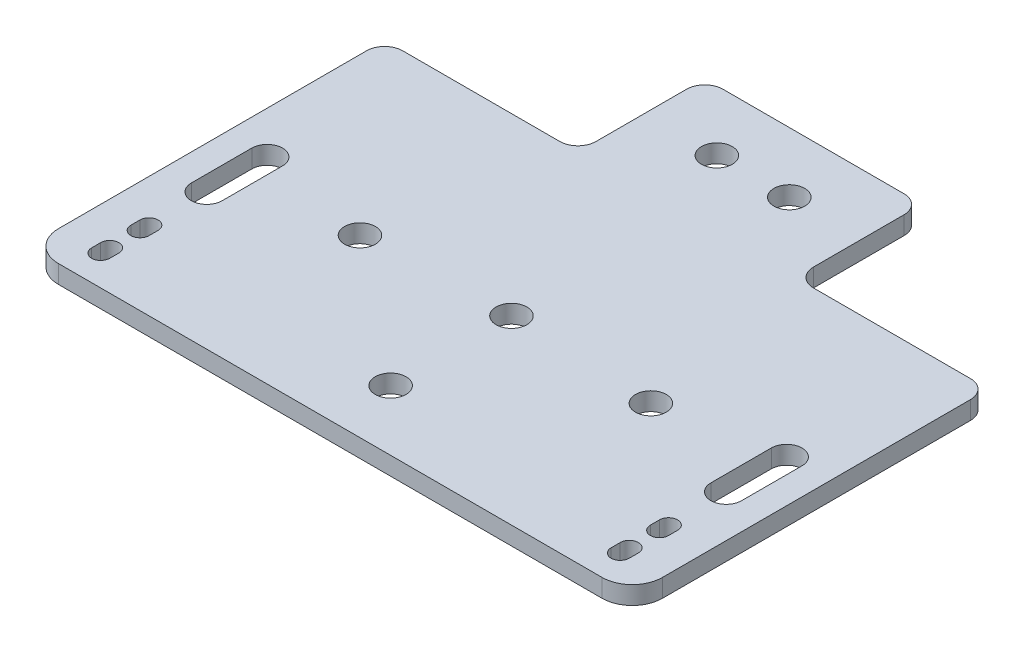
from build123d import *

# Parameters (mm, degrees)
SKETCH1_R           = 2.55
BOSS_EXTRUDE1_DEPTH = 3


with BuildPart() as part:
    # Sketch1 → Boss-Extrude1 (new body)
    with BuildSketch(Plane(origin=(0, 0, 0), x_dir=(1, 0, 0), z_dir=(0, 1, 0))):
        with BuildLine():
            Line((-19.389943983, 28.212319901), (10.610056017, 28.212319901))
            ThreePointArc((10.610056017, 28.212319901), (12.731376361, 27.333640245), (13.610056017, 25.212319901))
            Line((13.610056017, 25.212319901), (13.610056017, 10.212319901))
            ThreePointArc((13.610056017, 10.212319901), (14.488735674, 8.090999558), (16.610056017, 7.212319901))
            Line((16.610056017, 7.212319901), (32.610056017, 7.212319901))
            Line((32.610056017, 7.212319901), (42.610056017, 7.212319901))
            ThreePointArc((42.610056017, 7.212319901), (44.731376361, 6.333640245), (45.610056017, 4.212319901))
            Line((45.610056017, 4.212319901), (45.610056017, -46.787680099))
            ThreePointArc((45.610056017, -46.787680099), (44.145589923, -50.323214005), (40.610056017, -51.787680099))
            Line((40.610056017, -51.787680099), (-49.389943983, -51.787680099))
            ThreePointArc((-49.389943983, -51.787680099), (-52.925477889, -50.323214005), (-54.389943983, -46.787680099))
            Line((-54.389943983, -46.787680099), (-54.389943983, 4.212319901))
            ThreePointArc((-54.389943983, 4.212319901), (-53.511264326, 6.333640245), (-51.389943983, 7.212319901))
            Line((-51.389943983, 7.212319901), (-41.389943983, 7.212319901))
            Line((-41.389943983, 7.212319901), (-25.389943983, 7.212319901))
            ThreePointArc((-25.389943983, 7.212319901), (-23.268623639, 8.090999558), (-22.389943983, 10.212319901))
            Line((-22.389943983, 10.212319901), (-22.389943983, 25.212319901))
            ThreePointArc((-22.389943983, 25.212319901), (-21.511264326, 27.333640245), (-19.389943983, 28.212319901))
        make_face()
        with Locations((-10.389943983, 18.212319901)):
            Circle(SKETCH1_R, mode=Mode.SUBTRACT)
        with Locations((1.610056017, 18.212319901)):
            Circle(SKETCH1_R, mode=Mode.SUBTRACT)
        with Locations((-4.389943983, -41.787680099)):
            Circle(SKETCH1_R, mode=Mode.SUBTRACT)
        with Locations((-4.389943983, -21.787680099)):
            Circle(SKETCH1_R, mode=Mode.SUBTRACT)
        with Locations((-28.469943983, -22.787680099)):
            Circle(SKETCH1_R, mode=Mode.SUBTRACT)
        with Locations((19.690056017, -22.787680099)):
            Circle(SKETCH1_R, mode=Mode.SUBTRACT)
        with BuildLine():
            Line((40.110056017, -38.787680099), (40.110056017, -40.287680099))
            ThreePointArc((40.110056017, -40.287680099), (38.610056017, -41.787680099), (37.110056017, -40.287680099))
            Line((37.110056017, -40.287680099), (37.110056017, -38.787680099))
            ThreePointArc((37.110056017, -38.787680099), (38.610056017, -37.287680099), (40.110056017, -38.787680099))
        make_face(mode=Mode.SUBTRACT)
        with BuildLine():
            Line((37.110056017, -46.787680099), (37.110056017, -45.287680099))
            ThreePointArc((37.110056017, -45.287680099), (38.610056017, -43.787680099), (40.110056017, -45.287680099))
            Line((40.110056017, -45.287680099), (40.110056017, -46.787680099))
            ThreePointArc((40.110056017, -46.787680099), (38.610056017, -48.287680099), (37.110056017, -46.787680099))
        make_face(mode=Mode.SUBTRACT)
        with BuildLine():
            Line((41.160056017, -19.229266089), (41.160056017, -29.229266089))
            ThreePointArc((41.160056017, -29.229266089), (38.610056017, -31.779266089), (36.060056017, -29.229266089))
            Line((36.060056017, -29.229266089), (36.060056017, -19.229266089))
            ThreePointArc((36.060056017, -19.229266089), (38.610056017, -16.679266089), (41.160056017, -19.229266089))
        make_face(mode=Mode.SUBTRACT)
        with BuildLine():
            Line((-45.889943983, -38.787680099), (-45.889943983, -40.287680099))
            ThreePointArc((-45.889943983, -40.287680099), (-47.389943983, -41.787680099), (-48.889943983, -40.287680099))
            Line((-48.889943983, -40.287680099), (-48.889943983, -38.787680099))
            ThreePointArc((-48.889943983, -38.787680099), (-47.389943983, -37.287680099), (-45.889943983, -38.787680099))
        make_face(mode=Mode.SUBTRACT)
        with BuildLine():
            Line((-48.889943983, -46.787680099), (-48.889943983, -45.287680099))
            ThreePointArc((-48.889943983, -45.287680099), (-47.389943983, -43.787680099), (-45.889943983, -45.287680099))
            Line((-45.889943983, -45.287680099), (-45.889943983, -46.787680099))
            ThreePointArc((-45.889943983, -46.787680099), (-47.389943983, -48.287680099), (-48.889943983, -46.787680099))
        make_face(mode=Mode.SUBTRACT)
        with BuildLine():
            Line((-44.839943983, -19.229266089), (-44.839943983, -29.229266089))
            ThreePointArc((-44.839943983, -29.229266089), (-47.389943983, -31.779266089), (-49.939943983, -29.229266089))
            Line((-49.939943983, -29.229266089), (-49.939943983, -19.229266089))
            ThreePointArc((-49.939943983, -19.229266089), (-47.389943983, -16.679266089), (-44.839943983, -19.229266089))
        make_face(mode=Mode.SUBTRACT)
    extrude(amount=BOSS_EXTRUDE1_DEPTH)


solid = part.part
